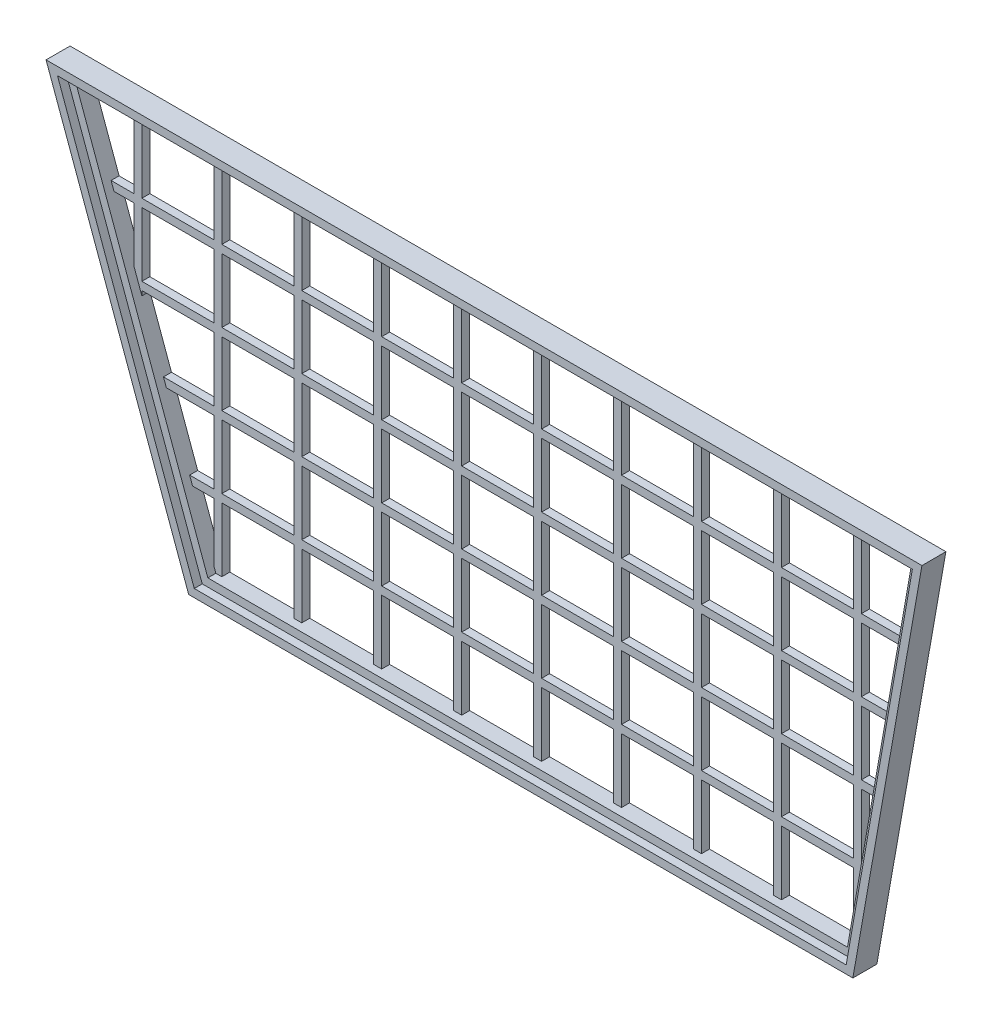
from build123d import *

# Parameters (mm, degrees)
BOSS_EXTRU_1_DEPTH         = 3
ENL_V_MAT_EXTRU_1_DEPTH    = 1
ESQUISSE3_W                = 1
ESQUISSE3_H                = 46.165382348
BOSS_EXTRU_2_DEPTH         = 1
R_P_TITION_LIN_AIRE1_COUNT = 10
R_P_TITION_LIN_AIRE1_PITCH = 10
ESQUISSE4_W                = 115.142225127
ESQUISSE4_H                = 1
BOSS_EXTRU_3_DEPTH         = 1
R_P_TITION_LIN_AIRE2_COUNT = 4
R_P_TITION_LIN_AIRE2_PITCH = 9
ESQUISSE6_W                = 145.186811134
ESQUISSE6_H                = 82.250288406
ENL_V_MAT_EXTRU_2_DEPTH    = 4


with BuildPart() as part:
    # Esquisse1 → Boss.-Extru.1 (new body)
    with BuildSketch(Plane.XY):
        Polygon((-47.221929914, 24.410148906), (-29.387388435, -24.589851094), (53.691225904, -24.589851094), (62.331247959, 24.410148906), align=None)
        Polygon((-27.986973358, -22.589851094), (52.013026642, -22.589851094), (59.947740773, 22.410148906), (-44.3656339, 22.410148906), align=None, mode=Mode.SUBTRACT)
    extrude(amount=BOSS_EXTRU_1_DEPTH)

    # Esquisse2 → Enlèv. mat.-Extru.1 (cut)
    with BuildSketch(Plane.XY.offset(3)):
        Polygon((61.139494366, 23.410148906), (-45.793781907, 23.410148906), (-28.687180897, -23.589851094), (52.852126273, -23.589851094), align=None)
        Polygon((59.947740773, 22.410148906), (-44.3656339, 22.410148906), (-27.986973358, -22.589851094), (52.013026642, -22.589851094), align=None, mode=Mode.SUBTRACT)
    extrude(amount=-ENL_V_MAT_EXTRU_1_DEPTH, mode=Mode.SUBTRACT)

    # Esquisse3 → Boss.-Extru.2 (add)
    with BuildSketch(Plane.XY):
        with Locations((-37.740481402, -0.672542268)):
            Rectangle(ESQUISSE3_W, ESQUISSE3_H)
    boss_extru_2 = extrude(amount=BOSS_EXTRU_2_DEPTH)

    # Répétition linéaire1: Boss.-Extru.2 ×10
    with Locations(*[(i * R_P_TITION_LIN_AIRE1_PITCH, 0, 0) for i in range(1, R_P_TITION_LIN_AIRE1_COUNT)]):
        add(boss_extru_2)

    # Esquisse4 → Boss.-Extru.3 (add)
    with BuildSketch(Plane.XY):
        with Locations((11.695067266, 12.910148906)):
            Rectangle(ESQUISSE4_W, ESQUISSE4_H)
    boss_extru_3 = extrude(amount=BOSS_EXTRU_3_DEPTH)

    # Répétition linéaire2: Boss.-Extru.3 ×4
    with Locations(*[(0, -i * R_P_TITION_LIN_AIRE2_PITCH, 0) for i in range(1, R_P_TITION_LIN_AIRE2_COUNT)]):
        add(boss_extru_3)

    # Esquisse6 → Enlèv. mat.-Extru.2 (cut, through all)
    with BuildSketch(Plane.XY.offset(3)):
        with Locations((8.362981272, 0)):
            Rectangle(ESQUISSE6_W, ESQUISSE6_H)
        Polygon((62.331247959, 24.410148906), (-47.221929914, 24.410148906), (-29.387388435, -24.589851094), (53.691225904, -24.589851094), align=None, mode=Mode.SUBTRACT)
    extrude(amount=-ENL_V_MAT_EXTRU_2_DEPTH, mode=Mode.SUBTRACT)


solid = part.part
